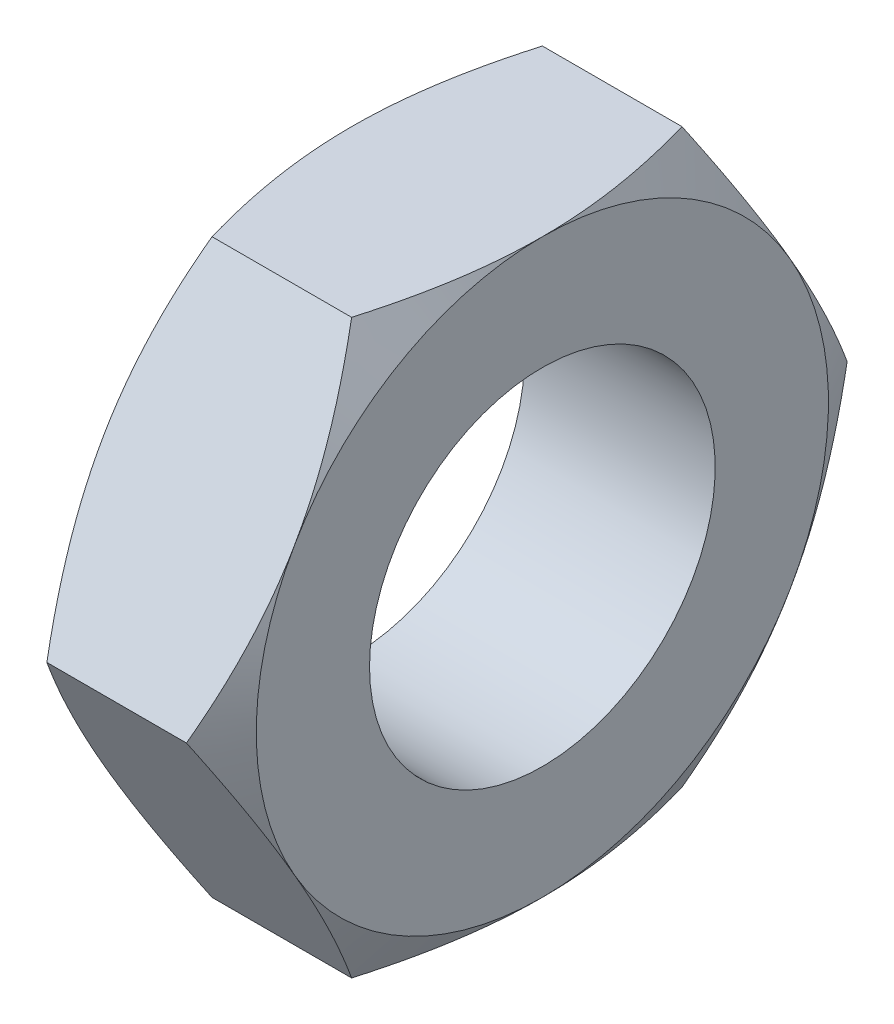
from build123d import *

# Parameters (mm, degrees)
BOSS_EXTRUDE1_DEPTH = 8
TAPPED_HOLE1_D      = 14.5


with BuildPart() as part:
    # Sketch1 → Boss-Extrude1 (new body)
    with BuildSketch(Plane(origin=(0, 0, 0), x_dir=(0, 0, -1), z_dir=(1, 0, 0))):
        Polygon((13.856406461, 0), (6.92820323, 12), (-6.92820323, 12), (-13.856406461, 0), (-6.92820323, -12), (6.92820323, -12), align=None)
    extrude(amount=BOSS_EXTRUDE1_DEPTH)

    # Tapped Hole1 (through all)
    with Locations(Plane.ZY):
        with Locations((0, 0)):
            Hole(TAPPED_HOLE1_D / 2)

    # Sketch6 → Cut-Revolve1 (revolve, cut)
    with BuildSketch(Plane(origin=(0, 0, 0), x_dir=(1, 0, 0), z_dir=(0, 1, 0))):
        Polygon((0, 12), (1.07179677, 13.856406461), (0, 13.856406461), align=None)
    cut_revolve1 = revolve(axis=Axis((0, 0, 0), (1, 0, 0)), mode=Mode.SUBTRACT)

    # Mirror1: Cut-Revolve1 across plane
    add(cut_revolve1.mirror(Plane.ZY.offset(-4)), mode=Mode.SUBTRACT)


solid = part.part
